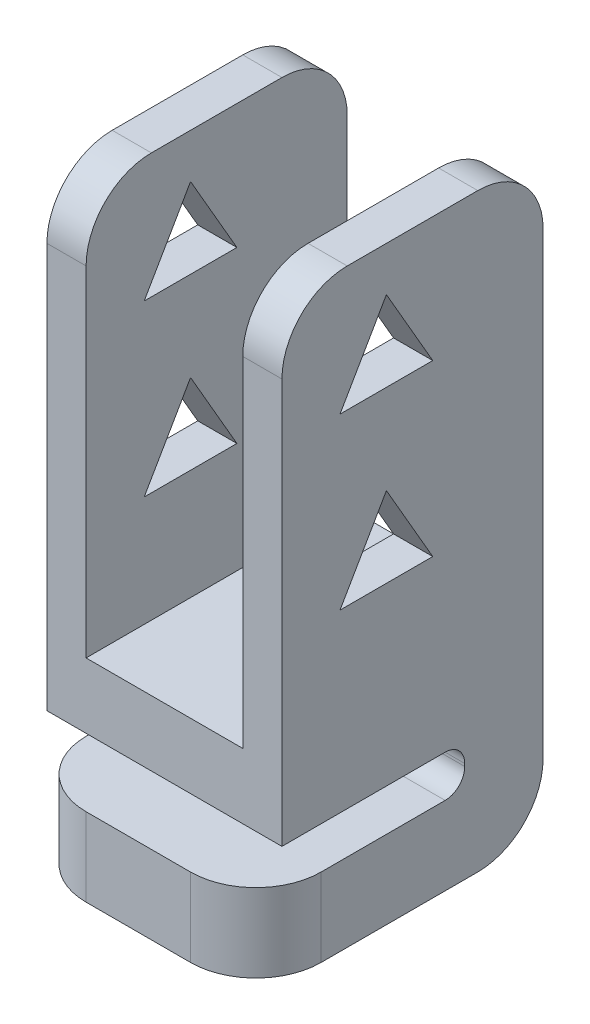
from build123d import *

# Parameters (mm, degrees)
BOSS_EXTRUDE1_DEPTH     = 4.5
CUT_EXTRUDE1_DEPTH      = 10
CUT_EXTRUDE2_DEPTH      = 5.5
CUT_EXTRUDE2_DEPTH_BACK = 5.5
FILLET1_R               = 2.5
FILLET2_R               = 0.75


with BuildPart() as part:
    # Sketch2 → Boss-Extrude1 (new body, symmetric)
    with BuildSketch(Plane(origin=(0, 0, 0), x_dir=(0, 0, -1), z_dir=(1, 0, 0))):
        Polygon((2, -9), (2, -10.6), (-6, -10.6), (-6, -13.6), (5, -13.6), (5, -9), (5, 9), (-5, 9), (-5, -9), align=None)
    extrude(amount=BOSS_EXTRUDE1_DEPTH, both=True)

    # Sketch3 → Cut-Extrude1 (cut)
    with BuildSketch(Plane.XY.offset(5)):
        Polygon((-3, 6.5), (-3, -6.5), (3, -6.5), (3, 6.5), (3, 9), (-3, 9), align=None)
    extrude(amount=-CUT_EXTRUDE1_DEPTH, mode=Mode.SUBTRACT)

    # Sketch4 → Cut-Extrude2 (cut, two sides)
    with BuildSketch(Plane(origin=(0, 0, 0), x_dir=(0, 0, -1), z_dir=(1, 0, 0))) as cut_extrude2_sk:
        Polygon((0.775352078, 4.225), (-1, 7.3), (-2.775352078, 4.225), align=None)
        Polygon((0.775352078, -2.275), (-1, 0.8), (-2.775352078, -2.275), align=None)
    extrude(amount=CUT_EXTRUDE2_DEPTH, mode=Mode.SUBTRACT)
    extrude(cut_extrude2_sk.sketch, amount=-CUT_EXTRUDE2_DEPTH_BACK, mode=Mode.SUBTRACT)

    # Fillet1
    fillet1_edges = [part.edges().sort_by_distance(p)[0] for p in [
        (0, -13.6, -5),
        (3.75, 9, 5),
        (3.75, 9, -5),
        (4.5, -12.1, 6),
        (-3.75, 9, 5),
        (-3.75, 9, -5),
        (-4.5, -12.1, 6),
    ]]
    fillet(fillet1_edges, radius=FILLET1_R)

    # Fillet2
    fillet2_edges = [part.edges().sort_by_distance(p)[0] for p in [
        (0, -10.6, -2),
        (0, -9, -2),
    ]]
    fillet(fillet2_edges, radius=FILLET2_R)


solid = part.part
